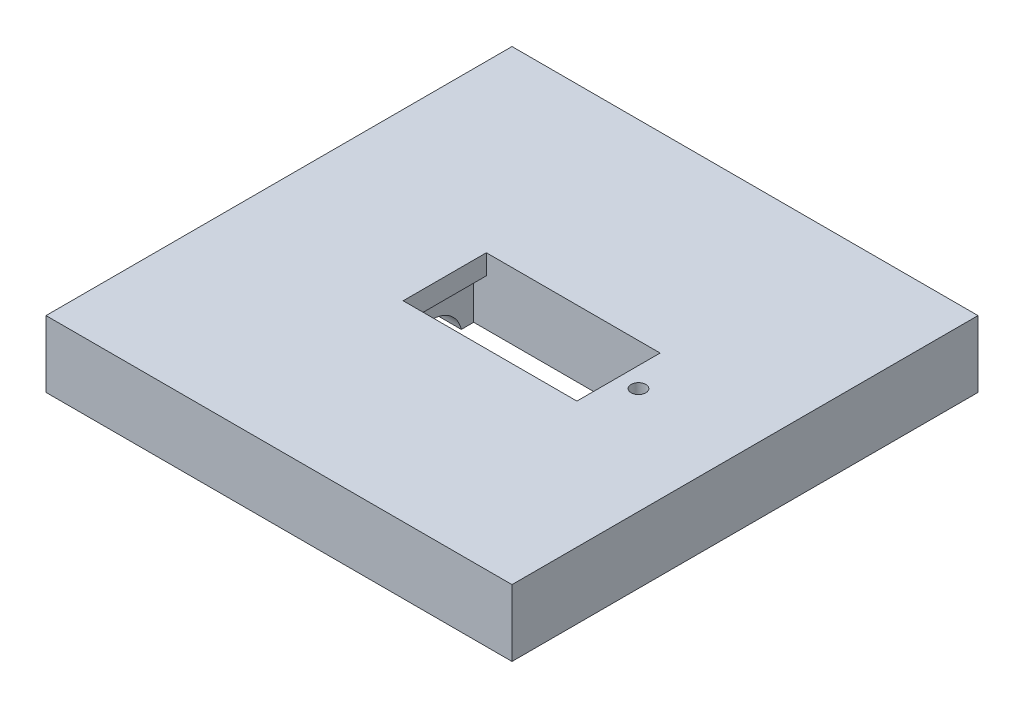
from build123d import *

# Parameters (mm, degrees)
CROQUIS1_W              = 64
CROQUIS1_H              = 64
SALIENTE_EXTRUIR1_DEPTH = 60
CROQUIS2_W              = 70
CROQUIS2_H              = 70
CROQUIS2_W_2            = 64
CROQUIS2_H_2            = 64
SALIENTE_EXTRUIR2_DEPTH = 64
CORTAR_EXTRUIR1_DEPTH   = 21
CROQUIS5_R              = 1.1
CORTAR_EXTRUIR2_DEPTH   = 10
CORTAR_EXTRUIR3_REACH   = 30
CROQUIS10_R             = 4.5
CROQUIS11_W             = 70
CROQUIS11_H             = 70
CORTAR_EXTRUIR4_DEPTH   = 30
CROQUIS12_W             = 23
CROQUIS12_H             = 12.2
CORTAR_EXTRUIR5_DEPTH   = 21
CORTAR_EXTRUIR6_REACH   = 30
CROQUIS13_R             = 4.5
CROQUIS14_R             = 1.1
CORTAR_EXTRUIR7_DEPTH   = 10
CROQUIS15_R             = 3.7
CORTAR_EXTRUIR8_DEPTH   = 10
CROQUIS16_W             = 64
CROQUIS16_H             = 64
CORTAR_EXTRUIR9_DEPTH   = 5
CROQUIS17_W             = 12.5
CROQUIS17_H             = 12.998685397
CORTAR_EXTRUIR10_DEPTH  = 5
CORTAR_EXTRUIR11_REACH  = 72
CROQUIS18_W             = 70
CROQUIS18_H             = 9
CROQUIS18_H_2           = 5.000169364
CORTAR_EXTRUIR13_DEPTH  = 5
CORTAR_EXTRUIR14_REACH  = 12
CROQUIS21_W             = 81.467019472
CROQUIS21_H             = 81.467019472
CORTAR_EXTRUIR16_REACH  = 5.001
CROQUIS23_W             = 3.1
CROQUIS23_H             = 12.5


with BuildPart() as part:
    # Croquis1 → Saliente-Extruir1 (new body)
    with BuildSketch(Plane(origin=(0, 0, 0), x_dir=(1, 0, 0), z_dir=(0, 1, 0))):
        Rectangle(CROQUIS1_W, CROQUIS1_H)
    extrude(amount=SALIENTE_EXTRUIR1_DEPTH)

    # Croquis2 → Saliente-Extruir2 (add)
    with BuildSketch(Plane(origin=(0, 0, 0), x_dir=(1, 0, 0), z_dir=(0, 1, 0))):
        Rectangle(CROQUIS2_W, CROQUIS2_H)
        Rectangle(CROQUIS2_W_2, CROQUIS2_H_2, mode=Mode.SUBTRACT)
    extrude(amount=SALIENTE_EXTRUIR2_DEPTH)

    # Croquis4 → Cortar-Extruir1 (cut)
    with BuildSketch(Plane(origin=(0, 60, 0), x_dir=(1, 0, 0), z_dir=(0, 1, 0))):
        Polygon((-7, 6), (-7, -6), (-7, -6.25), (16, -6.25), (16, -6), (16, 6), (16, 6.25), (-7, 6.25), align=None)
    extrude(amount=-CORTAR_EXTRUIR1_DEPTH, mode=Mode.SUBTRACT)

    # Croquis5 → Cortar-Extruir2 (cut)
    with BuildSketch(Plane(origin=(0, 60, 0), x_dir=(1, 0, 0), z_dir=(0, 1, 0))):
        with Locations((19, 0)):
            Circle(CROQUIS5_R)
        with Locations((-9, 0)):
            Circle(CROQUIS5_R)
    extrude(amount=-CORTAR_EXTRUIR2_DEPTH, mode=Mode.SUBTRACT)

    # Croquis10 → Cortar-Extruir3 (cut, up to next)
    with BuildSketch(Plane(origin=(-7, 0, 0), x_dir=(0, 0, -1), z_dir=(1, 0, 0)), mode=Mode.PRIVATE) as cortar_extruir3_sk1:
        with Locations((0, 44)):
            Circle(CROQUIS10_R)
    cortar_extruir3_tool1 = extrude(cortar_extruir3_sk1.sketch, amount=-CORTAR_EXTRUIR3_REACH, mode=Mode.PRIVATE) & part.part
    add(cortar_extruir3_tool1.solids().sort_by_distance((-7, 44, 0))[0], mode=Mode.SUBTRACT)

    # Croquis11 → Cortar-Extruir4 (cut)
    with BuildSketch(Plane.XZ):
        Rectangle(CROQUIS11_W, CROQUIS11_H)
    extrude(amount=-CORTAR_EXTRUIR4_DEPTH, mode=Mode.SUBTRACT)

    # Croquis12 → Cortar-Extruir5 (cut)
    with BuildSketch(Plane.XZ.offset(-30)):
        with Locations((4.5, 22.1)):
            Rectangle(CROQUIS12_W, CROQUIS12_H)
    extrude(amount=-CORTAR_EXTRUIR5_DEPTH, mode=Mode.SUBTRACT)

    # Croquis13 → Cortar-Extruir6 (cut, up to next)
    with BuildSketch(Plane(origin=(-7, 0, 0), x_dir=(0, 0, -1), z_dir=(1, 0, 0)), mode=Mode.PRIVATE) as cortar_extruir6_sk1:
        with Locations((-22.1, 46)):
            Circle(CROQUIS13_R)
    cortar_extruir6_tool1 = extrude(cortar_extruir6_sk1.sketch, amount=-CORTAR_EXTRUIR6_REACH, mode=Mode.PRIVATE) & part.part
    add(cortar_extruir6_tool1.solids().sort_by_distance((-7, 46, 22.1))[0], mode=Mode.SUBTRACT)

    # Croquis14 → Cortar-Extruir7 (cut)
    with BuildSketch(Plane.XZ.offset(-30)):
        with Locations((19, 22.1)):
            Circle(CROQUIS14_R)
        with Locations((-9, 22.1)):
            Circle(CROQUIS14_R)
    extrude(amount=-CORTAR_EXTRUIR7_DEPTH, mode=Mode.SUBTRACT)

    # Croquis15 → Cortar-Extruir8 (cut)
    with BuildSketch(Plane.XZ.offset(-30)):
        with Locations((0, -22.1)):
            Circle(CROQUIS15_R)
    extrude(amount=-CORTAR_EXTRUIR8_DEPTH, mode=Mode.SUBTRACT)

    # Croquis16 → Cortar-Extruir9 (cut)
    with BuildSketch(Plane(origin=(0, 60, 0), x_dir=(1, 0, 0), z_dir=(0, 1, 0))):
        Rectangle(CROQUIS16_W, CROQUIS16_H)
    extrude(amount=-CORTAR_EXTRUIR9_DEPTH, mode=Mode.SUBTRACT)

    # Croquis17 → Cortar-Extruir10 (cut)
    with BuildSketch(Plane(origin=(-7, 0, 0), x_dir=(0, 0, -1), z_dir=(1, 0, 0))):
        with Locations((0, 45.499342699)):
            Rectangle(CROQUIS17_W, CROQUIS17_H)
    extrude(amount=-CORTAR_EXTRUIR10_DEPTH, mode=Mode.SUBTRACT)

    # Croquis18 → Cortar-Extruir11 (cut, up to next)
    with BuildSketch(Plane(origin=(35, 0, 0), x_dir=(0, 0, -1), z_dir=(1, 0, 0)), mode=Mode.PRIVATE) as cortar_extruir11_sk1:
        with Locations((0, 59.5)):
            Rectangle(CROQUIS18_W, CROQUIS18_H)
    cortar_extruir11_tool1 = extrude(cortar_extruir11_sk1.sketch, amount=-CORTAR_EXTRUIR11_REACH, mode=Mode.PRIVATE) & part.part
    add(cortar_extruir11_tool1.solids().sort_by_distance((35, 59.5, 0))[0], mode=Mode.SUBTRACT)
    # Croquis18 → Cortar-Extruir11 (cut, up to next)
    with BuildSketch(Plane(origin=(35, 0, 0), x_dir=(0, 0, -1), z_dir=(1, 0, 0)), mode=Mode.PRIVATE) as cortar_extruir11_sk2:
        with Locations((0, 32.500084682)):
            Rectangle(CROQUIS18_W, CROQUIS18_H_2)
    cortar_extruir11_tool2 = extrude(cortar_extruir11_sk2.sketch, amount=-CORTAR_EXTRUIR11_REACH, mode=Mode.PRIVATE) & part.part
    add(cortar_extruir11_tool2.solids().sort_by_distance((35, 32.500085, 0))[0], mode=Mode.SUBTRACT)

    # Croquis19 → Cortar-Extruir13 (cut)
    with BuildSketch(Plane(origin=(-7, 0, 0), x_dir=(0, 0, -1), z_dir=(1, 0, 0))):
        Polygon((-16, 51), (-28.2, 51), (-28.2, 38.000169364), (-22.1, 38.000169364), (-16, 38.000169364), align=None)
    extrude(amount=-CORTAR_EXTRUIR13_DEPTH, mode=Mode.SUBTRACT)

    # Croquis21 → Cortar-Extruir14 (cut, up to next)
    with BuildSketch(Plane(origin=(0, 45.000169364, 0), x_dir=(-1, 0, 0), z_dir=(0, -1, 0)), mode=Mode.PRIVATE) as cortar_extruir14_sk1:
        with Locations((0.076423095, -0.764230952)):
            Rectangle(CROQUIS21_W, CROQUIS21_H)
    cortar_extruir14_tool1 = extrude(cortar_extruir14_sk1.sketch, amount=CORTAR_EXTRUIR14_REACH, mode=Mode.PRIVATE) & part.part
    add(cortar_extruir14_tool1.solids().sort_by_distance((-0.076423, 45.000169, 0.764231))[0], mode=Mode.SUBTRACT)

    # Croquis23 → Cortar-Extruir16 (cut, up to next)
    with BuildSketch(Plane.XZ.offset(-51.998685397), mode=Mode.PRIVATE) as cortar_extruir16_sk1:
        with Locations((-8.55, 0)):
            Rectangle(CROQUIS23_W, CROQUIS23_H)
    cortar_extruir16_tool1 = extrude(cortar_extruir16_sk1.sketch, amount=-CORTAR_EXTRUIR16_REACH, mode=Mode.PRIVATE) & part.part
    add(cortar_extruir16_tool1.solids().sort_by_distance((-8.55, 51.998685, 0))[0], mode=Mode.SUBTRACT)


solid = part.part
